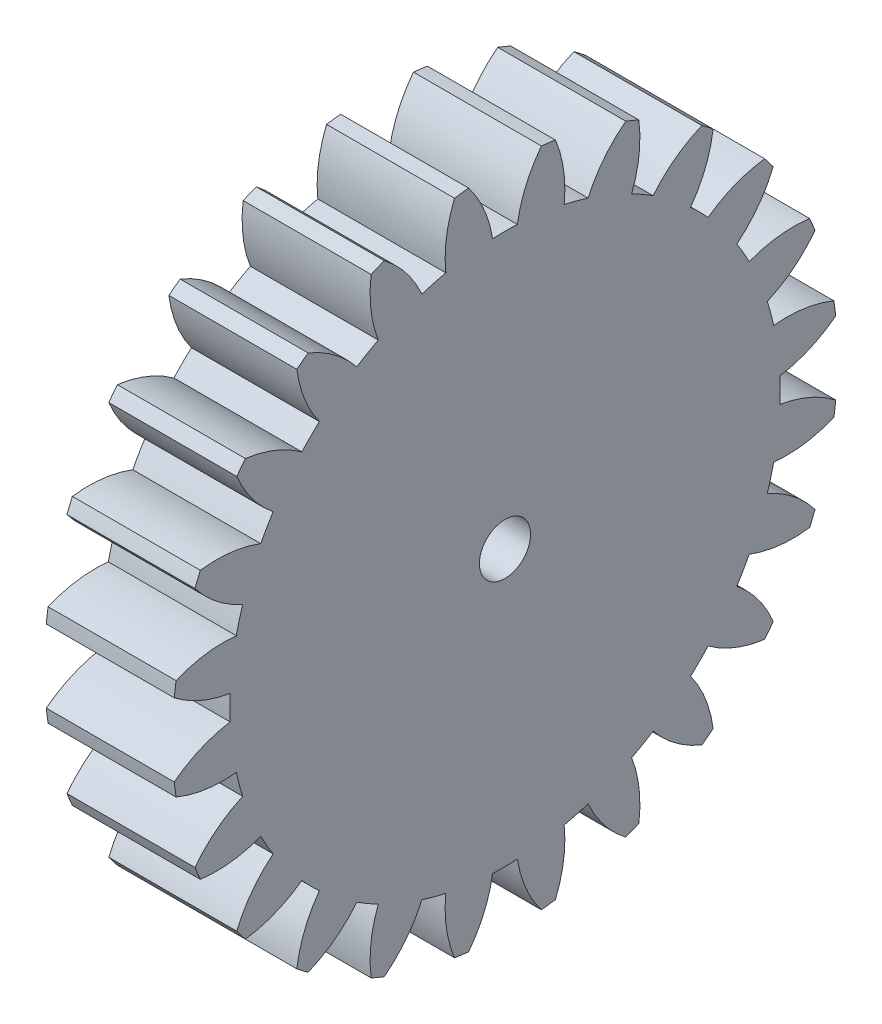
from build123d import *

# Parameters (mm, degrees)
BASPROSKE_W     = 5
BASPROSKE_H     = 13
TOOTHCUT_DEPTH  = 20.052558883
TEETHCUTS_COUNT = 24
TEETHCUTS_ANGLE = 345
BORSKE_R        = 1
BORE_DEPTH      = 50.0000508


with BuildPart() as part:
    # BasProSke → Base-Revolve (revolve)
    with BuildSketch(Plane(origin=(0, 0, 0), x_dir=(1, 0, 0), z_dir=(0, 1, 0))):
        with Locations((2.5, 6.5)):
            Rectangle(BASPROSKE_W, BASPROSKE_H)
    revolve(axis=Axis((-10, 0, 0), (1, 0, 0)))

    # TooCutSke → ToothCut (cut, through all)
    with BuildSketch(Plane(origin=(0, 0, 0), x_dir=(0, 0, -1), z_dir=(1, 0, 0))):
        with BuildLine():
            ThreePointArc((0.483448384, 10.738122679), (0, 10.749), (-0.483448384, 10.738122679))
            ThreePointArc((-0.483448384, 10.738122679), (-0.821636462, 11.902754369), (-1.44092227, 12.945454344))
            ThreePointArc((-1.44092227, 12.945454344), (0, 13.0254), (1.44092227, 12.945454344))
            ThreePointArc((1.44092227, 12.945454344), (0.821636462, 11.902754369), (0.483448384, 10.738122679))
        make_face()
    toothcut = extrude(amount=TOOTHCUT_DEPTH, mode=Mode.SUBTRACT)

    # TeethCuts: ToothCut ×24 about axis
    teethcuts_axis = Axis((-10, 0, 0), (1, 0, 0))
    for i in range(1, TEETHCUTS_COUNT):
        add(toothcut.rotate(teethcuts_axis, i * TEETHCUTS_ANGLE / (TEETHCUTS_COUNT - 1)), mode=Mode.SUBTRACT)

    # BorSke → Bore (cut, symmetric)
    with BuildSketch(Plane(origin=(0, 0, 0), x_dir=(0, 0, -1), z_dir=(1, 0, 0))):
        Circle(BORSKE_R)
    extrude(amount=BORE_DEPTH, both=True, mode=Mode.SUBTRACT)


solid = part.part
